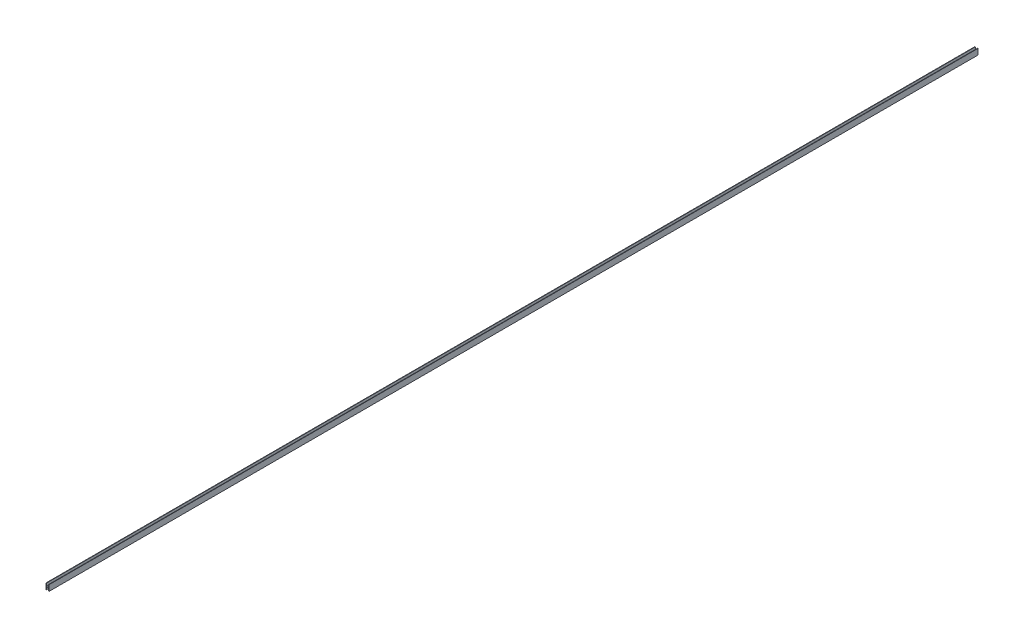
from build123d import *

# Parameters (mm, degrees)
SKETCH_1_W          = 8
SKETCH_1_H          = 15
EXTRUDE_1_DEPTH     = 2400
SKETCH_2_W          = 6
SKETCH_2_H          = 14
CUT_EXTRUDE_1_DEPTH = 2400


with BuildPart() as part:
    # 草图1 → 凸台-拉伸1 (new body)
    with BuildSketch(Plane.XY):
        Rectangle(SKETCH_1_W, SKETCH_1_H)
    extrude(amount=EXTRUDE_1_DEPTH)

    # 草图2 → 切除-拉伸1 (cut)
    with BuildSketch(Plane(origin=(0, 0, 0), x_dir=(-1, 0, 0), z_dir=(0, 0, -1))):
        with Locations((0, -7.5)):
            Rectangle(SKETCH_2_W, SKETCH_2_H)
        with Locations((0, 7.5)):
            Rectangle(SKETCH_2_W, SKETCH_2_H)
    extrude(amount=-CUT_EXTRUDE_1_DEPTH, mode=Mode.SUBTRACT)


solid = part.part
